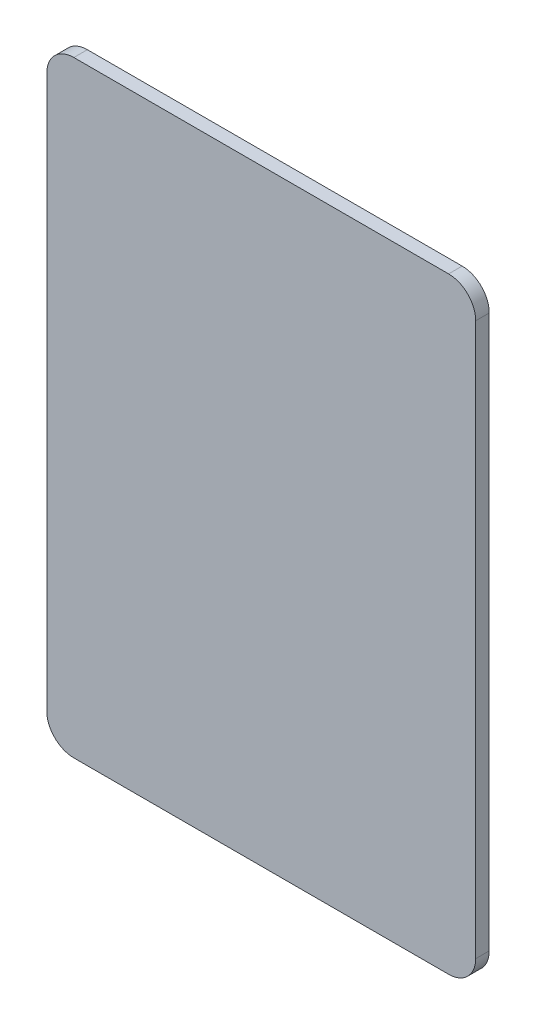
from build123d import *

# Parameters (mm, degrees)
SKETCH1_W           = 50.292
SKETCH1_H           = 71.12
BOSS_EXTRUDE1_DEPTH = 1.5875
FILLET1_R           = 3.175


with BuildPart() as part:
    # Sketch1 → Boss-Extrude1 (new body)
    with BuildSketch(Plane.XY):
        with Locations((25.146, 35.56)):
            Rectangle(SKETCH1_W, SKETCH1_H)
    extrude(amount=BOSS_EXTRUDE1_DEPTH)

    # Fillet1
    fillet1_edges = [part.edges().sort_by_distance(p)[0] for p in [
        (0, 71.12, 0.79375),
        (50.292, 71.12, 0.79375),
        (50.292, 0, 0.79375),
        (0, 0, 0.79375),
    ]]
    fillet(fillet1_edges, radius=FILLET1_R)


solid = part.part
